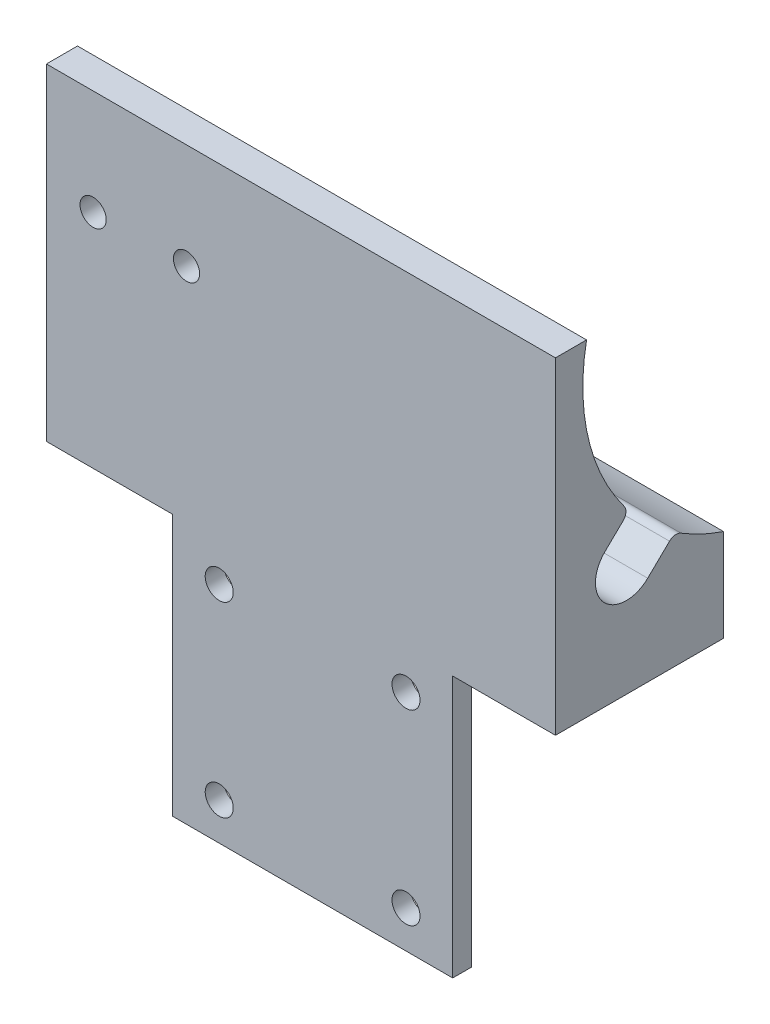
from build123d import *

# Parameters (mm, degrees)
SKETCH1_R               = 1.500000001
SKETCH1_R_2             = 1.5
BOSS_EXTRUDE2_DEPTH     = 4
SKETCH1_4_W             = 32
SKETCH1_4_H             = 35
SKETCH1_4_R             = 6.100000001
BOSS_EXTRUDE3_DEPTH     = 20
SKETCH2_R               = 1.5
CUT_EXTRUDE3_DEPTH      = 1
CUT_EXTRUDE3_DEPTH_BACK = 33
CUT_EXTRUDE4_DEPTH      = 5
CUT_EXTRUDE5_START      = -32
CUT_EXTRUDE5_DEPTH      = 5
CUT_EXTRUDE6_DEPTH      = 25
BOSS_EXTRUDE5_DEPTH     = 12.5
SKETCH7_R               = 1.4
CUT_EXTRUDE7_DEPTH      = 20
BOSS_EXTRUDE6_START     = -32
BOSS_EXTRUDE6_DEPTH     = 10
CUT_EXTRUDE8_DEPTH      = 43
SKETCH9_R               = 1.4
SKETCH9_W               = 32
SKETCH9_H               = 28
SKETCH9_R_2             = 1.500000001
BOSS_EXTRUDE7_DEPTH     = 2
SKETCH1_8_W             = 32
SKETCH1_8_H             = 27.5
SKETCH1_8_R             = 1.500000001
SKETCH1_8_R_2           = 1.5
CUT_EXTRUDE9_DEPTH      = 4
SKETCH11_W              = 1
SKETCH11_H              = 28
CUT_EXTRUDE13_DEPTH     = 27
CUT_EXTRUDE10_DEPTH     = 55.5


with BuildPart() as part:
    # Sketch1 → Boss-Extrude2 (new body)
    with BuildSketch(Plane.XY):
        Polygon((-16, 49), (-16, -46.5), (-14.969293645, -46.5), (-14.969293645, -42.160880121), (-15.92820323, -40.5), (-12.464101615, -34.5), (-5.535898385, -34.5), (-2.07179677, -40.5), (-5.535898385, -46.5), (5.535898385, -46.5), (2.090853862, -40.533007852), (5.457729166, -34.432863746), (12.425340481, -34.432863746), (15.909146138, -40.466992148), (15, -42.114193768), (15, -46.5), (16, -46.5), (16, 49), align=None)
        with Locations((10, 10)):
            Circle(SKETCH1_R, mode=Mode.SUBTRACT)
        with Locations((-10, -10)):
            Circle(SKETCH1_R, mode=Mode.SUBTRACT)
        with Locations((10, -10)):
            Circle(SKETCH1_R, mode=Mode.SUBTRACT)
        with Locations((-10, 10)):
            Circle(SKETCH1_R, mode=Mode.SUBTRACT)
        with Locations((0, -43.5)):
            Circle(SKETCH1_R_2, mode=Mode.SUBTRACT)
        with Locations((-8.5, -31.5)):
            Circle(SKETCH1_R_2, mode=Mode.SUBTRACT)
        with Locations((8.5, -31.5)):
            Circle(SKETCH1_R_2, mode=Mode.SUBTRACT)
    extrude(amount=BOSS_EXTRUDE2_DEPTH)

    # Sketch1_4 → Boss-Extrude3 (add)
    with BuildSketch(Plane.XY):
        with Locations((0, 31.5)):
            Rectangle(SKETCH1_4_W, SKETCH1_4_H)
        Polygon((0, 36.969655115), (9.5, 31.484827557), (9.5, 20.515172443), (0, 15.030344885), (-9.5, 20.515172443), (-9.5, 31.484827557), align=None, mode=Mode.SUBTRACT)
        Polygon((9.5, 31.484827557), (9.5, 20.515172443), (0, 15.030344885), (-9.5, 20.515172443), (-9.5, 31.484827557), (0, 36.969655115), align=None)
        with Locations((0, 26)):
            Circle(SKETCH1_4_R, mode=Mode.SUBTRACT)
        with Locations((0, 26)):
            Circle(SKETCH1_4_R)
    extrude(amount=-BOSS_EXTRUDE3_DEPTH)

    # Sketch2 → Cut-Extrude3 (cut, two sides)
    with BuildSketch(Plane.ZY.offset(16)) as cut_extrude3_sk:
        with Locations((-1.580023732, 25.999827557)):
            Circle(SKETCH2_R)
    extrude(amount=CUT_EXTRUDE3_DEPTH, mode=Mode.SUBTRACT)
    extrude(cut_extrude3_sk.sketch, amount=-CUT_EXTRUDE3_DEPTH_BACK, mode=Mode.SUBTRACT)

    # Sketch3 → Cut-Extrude4 (cut)
    with BuildSketch(Plane.ZY.offset(16)):
        with BuildLine():
            Line((0.716979622, 28.369168308), (-1.239134605, 30.265561192))
            ThreePointArc((-1.239134605, 30.265561192), (-1.539975782, 30.904899692), (-1.343104133, 31.583501701))
            ThreePointArc((-1.343104133, 31.583501701), (2.506062966, 39.867185425), (2.670991263, 49))
            Line((2.670991263, 49), (-20, 49))
            Line((-20, 49), (-20, 22.778106647))
            ThreePointArc((-20, 22.778106647), (-13.472070231, 23.458477945), (-7.432949471, 26.028651597))
            ThreePointArc((-7.432949471, 26.028651597), (-6.799957072, 26.171029415), (-6.212814046, 25.894960789))
            Line((-6.212814046, 25.894960789), (-3.877027086, 23.630486807))
            Line((-3.877027086, 23.630486807), (0.716979622, 28.369168308))
        make_face()
        with BuildLine():
            ThreePointArc((-3.877027086, 23.630486807), (0.789317018, 23.702824203), (0.716979622, 28.369168308))
            Line((0.716979622, 28.369168308), (-3.877027086, 23.630486807))
        make_face()
    extrude(amount=-CUT_EXTRUDE4_DEPTH, mode=Mode.SUBTRACT)

    # Sketch3_4 → Cut-Extrude5 (cut)
    with BuildSketch(Plane.ZY.offset(16).offset(CUT_EXTRUDE5_START)):
        with BuildLine():
            Line((0.716979622, 28.369168308), (-1.239134605, 30.265561192))
            ThreePointArc((-1.239134605, 30.265561192), (-1.539975782, 30.904899692), (-1.343104133, 31.583501701))
            ThreePointArc((-1.343104133, 31.583501701), (2.506062966, 39.867185425), (2.670991263, 49))
            Line((2.670991263, 49), (-20, 49))
            Line((-20, 49), (-20, 22.778106647))
            ThreePointArc((-20, 22.778106647), (-13.472070231, 23.458477945), (-7.432949471, 26.028651597))
            ThreePointArc((-7.432949471, 26.028651597), (-6.799957072, 26.171029415), (-6.212814046, 25.894960789))
            Line((-6.212814046, 25.894960789), (-3.877027086, 23.630486807))
            Line((-3.877027086, 23.630486807), (0.716979622, 28.369168308))
        make_face()
        with BuildLine():
            ThreePointArc((-3.877027086, 23.630486807), (0.789317018, 23.702824203), (0.716979622, 28.369168308))
            Line((0.716979622, 28.369168308), (-3.877027086, 23.630486807))
        make_face()
    extrude(amount=CUT_EXTRUDE5_DEPTH, mode=Mode.SUBTRACT)

    # Sketch5 → Cut-Extrude6 (cut, through all)
    with BuildSketch(Plane.XY.offset(4)):
        Polygon((-14.969293645, -42.160880121), (-15.92820323, -40.5), (-16, -40.500074436), (-16, -46.5), (-14.969293645, -46.5), align=None)
        Polygon((15, -42.114193768), (15.909146138, -40.466992148), (10.36687247, -40.472738184), (10.36687247, -46.5), (15, -46.5), align=None)
        Polygon((16, -40.466897954), (15.909146138, -40.466992148), (15, -42.114193768), (15, -46.5), (16, -46.5), align=None)
        Polygon((17.825288522, -40.465005559), (16, -40.466897954), (16, -46.5), (17.916172301, -46.5), align=None)
    extrude(amount=-CUT_EXTRUDE6_DEPTH, mode=Mode.SUBTRACT)

    # Sketch8 → Boss-Extrude5 (add)
    with BuildSketch(Plane.ZY.offset(16)):
        with BuildLine():
            ThreePointArc((-1.343104133, 31.583501701), (-1.539975782, 30.904899692), (-1.239134605, 30.265561192))
            Line((-1.239134605, 30.265561192), (0.716979622, 28.369168308))
            ThreePointArc((0.716979622, 28.369168308), (0.789317018, 23.702824203), (-3.877027086, 23.630486807))
            Line((-3.877027086, 23.630486807), (-6.212814046, 25.894960789))
            ThreePointArc((-6.212814046, 25.894960789), (-6.799957072, 26.171029415), (-7.432949471, 26.028651597))
            ThreePointArc((-7.432949471, 26.028651597), (-13.472070231, 23.458477945), (-20, 22.778106647))
            Line((-20, 22.778106647), (-20, 14))
            Line((-20, 14), (0, 14))
            Line((0, 14), (4, 14))
            Line((4, 14), (4, 49))
            Line((4, 49), (2.670991263, 49))
            ThreePointArc((2.670991263, 49), (2.506062966, 39.867185425), (-1.343104133, 31.583501701))
        make_face()
    extrude(amount=BOSS_EXTRUDE5_DEPTH)

    # Sketch7 → Cut-Extrude7 (cut)
    with BuildSketch(Plane.XY.offset(4)):
        with Locations((-13.5, 37.75)):
            Circle(SKETCH7_R)
        with Locations((-23.5, 37.75)):
            Circle(SKETCH7_R)
    extrude(amount=-CUT_EXTRUDE7_DEPTH, mode=Mode.SUBTRACT)

    # Sketch8_3 → Boss-Extrude6 (add)
    with BuildSketch(Plane.ZY.offset(16).offset(BOSS_EXTRUDE6_START)):
        with BuildLine():
            ThreePointArc((-1.343104133, 31.583501701), (-1.539975782, 30.904899692), (-1.239134605, 30.265561192))
            Line((-1.239134605, 30.265561192), (0.716979622, 28.369168308))
            ThreePointArc((0.716979622, 28.369168308), (0.789317018, 23.702824203), (-3.877027086, 23.630486807))
            Line((-3.877027086, 23.630486807), (-6.212814046, 25.894960789))
            ThreePointArc((-6.212814046, 25.894960789), (-6.799957072, 26.171029415), (-7.432949471, 26.028651597))
            ThreePointArc((-7.432949471, 26.028651597), (-13.472070231, 23.458477945), (-20, 22.778106647))
            Line((-20, 22.778106647), (-20, 14))
            Line((-20, 14), (0, 14))
            Line((0, 14), (4, 14))
            Line((4, 14), (4, 49))
            Line((4, 49), (2.670991263, 49))
            ThreePointArc((2.670991263, 49), (2.506062966, 39.867185425), (-1.343104133, 31.583501701))
        make_face()
    extrude(amount=-BOSS_EXTRUDE6_DEPTH)

    # Sketch8_4 → Cut-Extrude8 (cut, through all)
    with BuildSketch(Plane.ZY.offset(16)):
        with BuildLine():
            ThreePointArc((-1.343104133, 31.583501701), (-4.126373378, 28.519223025), (-7.432949471, 26.028651597))
            ThreePointArc((-7.432949471, 26.028651597), (-13.472070231, 23.458477945), (-20, 22.778106647))
            Line((-20, 22.778106647), (-20, 49))
            Line((-20, 49), (2.670991263, 49))
            ThreePointArc((2.670991263, 49), (2.506062966, 39.867185425), (-1.343104133, 31.583501701))
        make_face()
    extrude(amount=-CUT_EXTRUDE8_DEPTH, mode=Mode.SUBTRACT)

    # Sketch9 → Boss-Extrude7 (add)
    with BuildSketch(Plane.XY.offset(4)):
        Polygon((26, 14), (26, 49), (-28.5, 49), (-28.5, 14), (-16, 14), (16, 14), align=None)
        with Locations((-23.5, 37.75)):
            Circle(SKETCH9_R, mode=Mode.SUBTRACT)
        with Locations((-13.5, 37.75)):
            Circle(SKETCH9_R, mode=Mode.SUBTRACT)
        Rectangle(SKETCH9_W, SKETCH9_H)
        with Locations((-10, -10)):
            Circle(SKETCH9_R_2, mode=Mode.SUBTRACT)
        with Locations((-10, 10)):
            Circle(SKETCH9_R_2, mode=Mode.SUBTRACT)
        with Locations((10, -10)):
            Circle(SKETCH9_R_2, mode=Mode.SUBTRACT)
        with Locations((10, 10)):
            Circle(SKETCH9_R_2, mode=Mode.SUBTRACT)
    extrude(amount=BOSS_EXTRUDE7_DEPTH)

    # Sketch1_8 → Cut-Extrude9 (cut)
    with BuildSketch(Plane.XY):
        with Locations((0, 0.25)):
            Rectangle(SKETCH1_8_W, SKETCH1_8_H)
        with Locations((-10, 10)):
            Circle(SKETCH1_8_R, mode=Mode.SUBTRACT)
        with Locations((10, 10)):
            Circle(SKETCH1_8_R, mode=Mode.SUBTRACT)
        with Locations((10, -10)):
            Circle(SKETCH1_8_R, mode=Mode.SUBTRACT)
        with Locations((-10, -10)):
            Circle(SKETCH1_8_R, mode=Mode.SUBTRACT)
        Polygon((15, -13.5), (-14.969293645, -13.5), (-14.969293645, -38.839119879), (-12.464101615, -34.5), (-5.535898385, -34.5), (-2.07179677, -40.5), (-5.535898385, -46.5), (5.535898385, -46.5), (2.090853862, -40.533007852), (5.457729166, -34.432863746), (12.425340481, -34.432863746), (15, -38.892304845), align=None)
        with Locations((-8.5, -31.5)):
            Circle(SKETCH1_8_R_2, mode=Mode.SUBTRACT)
        with Locations((0, -43.5)):
            Circle(SKETCH1_8_R_2, mode=Mode.SUBTRACT)
        with Locations((8.5, -31.5)):
            Circle(SKETCH1_8_R_2, mode=Mode.SUBTRACT)
        Polygon((-14.969293645, -13.5), (-16, -13.5), (-16, -46.5), (-14.969293645, -46.5), (-14.969293645, -42.160880121), (-15.92820323, -40.5), (-14.969293645, -38.839119879), align=None)
        Polygon((16, -46.5), (16, -13.5), (15, -13.5), (15, -38.892304845), (15.909146138, -40.466992148), (15, -42.114193768), (15, -46.5), align=None)
    extrude(amount=CUT_EXTRUDE9_DEPTH, mode=Mode.SUBTRACT)

    # Sketch11 → Cut-Extrude13 (cut, through all)
    with BuildSketch(Plane.XY.offset(6)):
        with Locations((-15.5, 0)):
            Rectangle(SKETCH11_W, SKETCH11_H)
        with Locations((15.5, 0)):
            Rectangle(SKETCH11_W, SKETCH11_H)
    extrude(amount=-CUT_EXTRUDE13_DEPTH, mode=Mode.SUBTRACT)

    # Sketch10 → Cut-Extrude10 (cut, through all)
    with BuildSketch(Plane.ZY.offset(28.5)):
        with BuildLine():
            ThreePointArc((-12, 23.89439883), (-15.948490895, 22.967108487), (-20, 22.778106647))
            Line((-20, 22.778106647), (-20, 14))
            Line((-20, 14), (-12, 14))
            Line((-12, 14), (-12, 23.89439883))
        make_face()
    extrude(amount=-CUT_EXTRUDE10_DEPTH, mode=Mode.SUBTRACT)


solid = part.part
